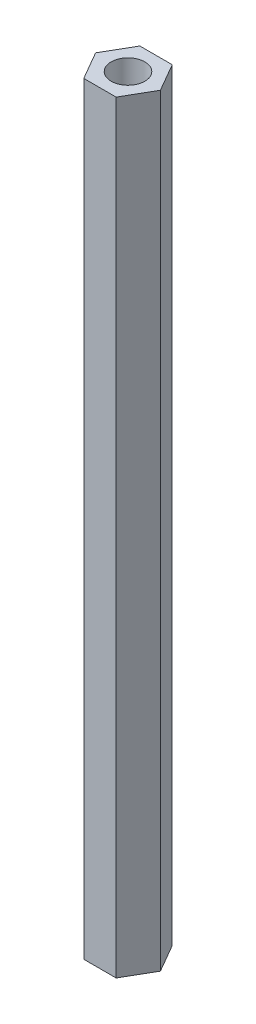
from build123d import *

# Parameters (mm, degrees)
EXTRUDE_1_DEPTH     = 68
SKETCH_2_R          = 1.5
CUT_EXTRUDE_1_DEPTH = 69


with BuildPart() as part:
    # 草图1 → 凸台-拉伸1 (new body)
    with BuildSketch(Plane(origin=(0, 0, 0), x_dir=(1, 0, 0), z_dir=(0, 1, 0))):
        Polygon((2.886751346, 0), (1.443375673, 2.5), (-1.443375673, 2.5), (-2.886751346, 0), (-1.443375673, -2.5), (1.443375673, -2.5), align=None)
    extrude(amount=EXTRUDE_1_DEPTH)

    # 草图2 → 切除-拉伸1 (cut, through all)
    with BuildSketch(Plane(origin=(0, 68, 0), x_dir=(1, 0, 0), z_dir=(0, 1, 0))):
        Circle(SKETCH_2_R)
    extrude(amount=-CUT_EXTRUDE_1_DEPTH, mode=Mode.SUBTRACT)


solid = part.part
